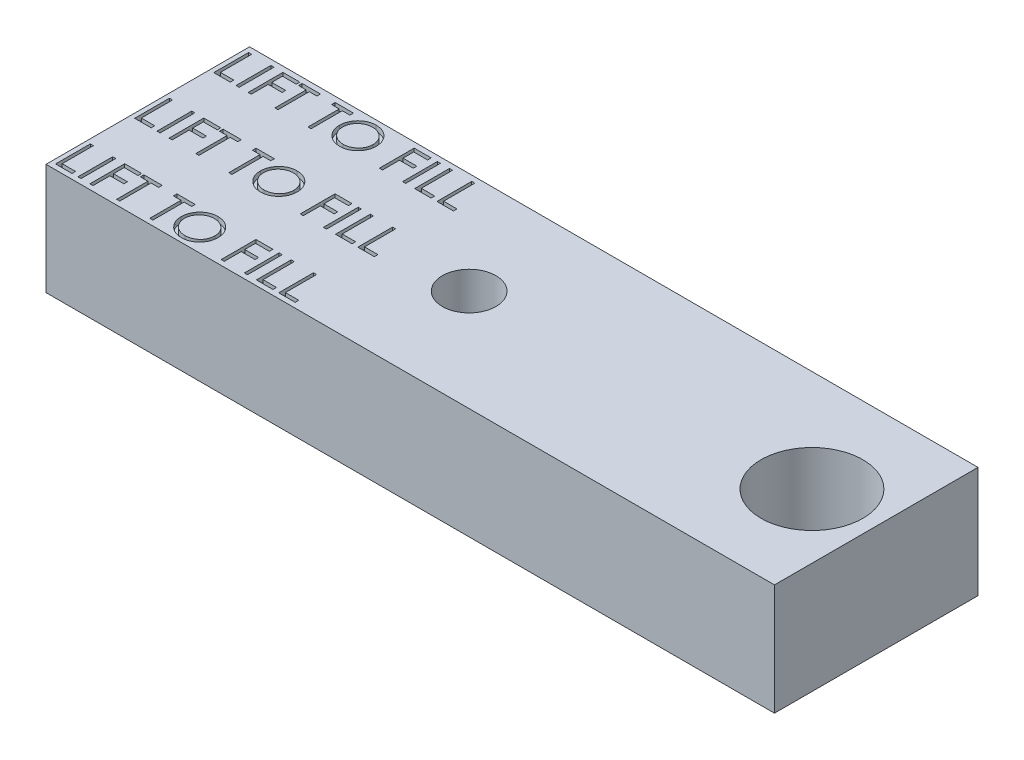
from build123d import *

# Parameters (mm, degrees)
SKETCH1_W           = 34.544
SKETCH1_H           = 9.652
BOSS_EXTRUDE1_DEPTH = 5.2705
SKETCH2_R           = 2.413
SKETCH2_R_2         = 1.27
CUT_EXTRUDE1_DEPTH  = 6.2705
SKETCH3_W           = 0.148166667
SKETCH3_H           = 1.651
SKETCH3_W_2         = 0.148166666
CUT_EXTRUDE2_DEPTH  = 0.254


with BuildPart() as part:
    # Sketch1 → Boss-Extrude1 (new body)
    with BuildSketch(Plane(origin=(0, 0, 0), x_dir=(1, 0, 0), z_dir=(0, 1, 0))):
        with Locations((17.272, 4.826)):
            Rectangle(SKETCH1_W, SKETCH1_H)
    extrude(amount=BOSS_EXTRUDE1_DEPTH)

    # Sketch2 → Cut-Extrude1 (cut, through all)
    with BuildSketch(Plane(origin=(0, 5.2705, 0), x_dir=(1, 0, 0), z_dir=(0, 1, 0))):
        with Locations((31.496, 4.826)):
            Circle(SKETCH2_R)
        with Locations((15.24, 4.826)):
            Circle(SKETCH2_R_2)
    extrude(amount=-CUT_EXTRUDE1_DEPTH, mode=Mode.SUBTRACT)

    # Sketch3 → Cut-Extrude2 (cut)
    with BuildSketch(Plane(origin=(0, 5.2705, 0), x_dir=(1, 0, 0), z_dir=(0, 1, 0))):
        Polygon((0.211666667, 9.394066324), (0.359833333, 9.394066324), (0.359833333, 7.912399657), (0.994833333, 7.912399657), (0.994833333, 7.743066324), (0.211666667, 7.743066324), align=None)
        with Locations((1.344083333, 8.568566324)):
            Rectangle(SKETCH3_W, SKETCH3_H)
        Polygon((1.8415, 9.394066324), (2.645833333, 9.394066324), (2.645833333, 9.224732991), (1.989666667, 9.224732991), (1.989666667, 8.716732991), (2.645833333, 8.716732991), (2.645833333, 8.547399657), (1.989666667, 8.547399657), (1.989666667, 7.743066324), (1.8415, 7.743066324), align=None)
        Polygon((2.751666667, 9.224732991), (2.751666667, 9.394066324), (3.6195, 9.394066324), (3.6195, 9.224732991), (3.259666667, 9.224732991), (3.259666667, 7.743066324), (3.1115, 7.743066324), (3.1115, 9.224732991), align=None)
        Polygon((4.318, 9.224732991), (4.318, 9.394066324), (5.185833333, 9.394066324), (5.185833333, 9.224732991), (4.826, 9.224732991), (4.826, 7.743066324), (4.677833333, 7.743066324), (4.677833333, 9.224732991), align=None)
        with BuildLine():
            add(Edge.make_bspline(
                [(6.212416667, 9.436399657), (6.242987576, 9.435625348), (6.303031364, 9.434104541), (6.391277266, 9.422463055), (6.475523124, 9.40232303), (6.556455209, 9.375499948), (6.633105468, 9.339718351), (6.706050842, 9.296469157), (6.775117774, 9.245299262), (6.839375345, 9.186604218), (6.898177809, 9.122741909), (6.949984249, 9.054589614), (6.993401914, 8.982559408), (7.029056809, 8.906867742), (7.057028811, 8.827685797), (7.076330908, 8.744591437), (7.088660647, 8.658123053), (7.090102101, 8.599146095), (7.090833333, 8.569227782)],
                knots=[0, 0, 0, 0, 9.1698e-05, 0.000180102, 0.000266419, 0.000351239, 0.000435435, 0.000519665, 0.000605259, 0.000692824, 0.000780368, 0.000865366, 0.000949198, 0.001032196, 0.00111598, 0.001200612, 0.00128775, 0.001377465, 0.001377465, 0.001377465, 0.001377465], degree=3))
            add(Edge.make_bspline(
                [(7.090833333, 8.569227782), (7.090102208, 8.539529855), (7.088661075, 8.480991801), (7.076316889, 8.395072136), (7.056957263, 8.312479354), (7.029316567, 8.233351333), (6.993831634, 8.157604602), (6.950124867, 8.08543847), (6.898641398, 8.016829279), (6.840051252, 7.952528648), (6.776180646, 7.893565555), (6.707673455, 7.842186965), (6.636070377, 7.797975957), (6.560449998, 7.76269943), (6.481815209, 7.734504161), (6.399462233, 7.715280563), (6.313776959, 7.702880589), (6.255345237, 7.701456712), (6.225645833, 7.700732991)],
                knots=[0, 0, 0, 0, 8.9055e-05, 0.000175537, 0.000259847, 0.00034321, 0.000426507, 0.000510339, 0.000595865, 0.000683431, 0.000770974, 0.000856237, 0.000939957, 0.001022955, 0.001106116, 0.001190104, 0.001276259, 0.001365313, 0.001365313, 0.001365313, 0.001365313], degree=3))
            add(Edge.make_bspline(
                [(6.225645833, 7.700732991), (6.195727676, 7.701463858), (6.136751024, 7.702904594), (6.050173982, 7.715254736), (5.967021252, 7.734567334), (5.887530625, 7.762167071), (5.811657774, 7.797836799), (5.73925431, 7.841330922), (5.670610849, 7.892939833), (5.6062965, 7.95151098), (5.547450521, 8.015273332), (5.496147169, 8.08359372), (5.452643266, 8.155131765), (5.417093305, 8.230085997), (5.388948728, 8.308094069), (5.369747683, 8.389676337), (5.357324639, 8.474367686), (5.355893058, 8.532031408), (5.355166667, 8.561290282)],
                knots=[0, 0, 0, 0, 8.9715e-05, 0.000176853, 0.000261807, 0.000345482, 0.000428779, 0.000512894, 0.000598421, 0.000685986, 0.00077353, 0.000858329, 0.000941878, 0.001024278, 0.001106815, 0.00119016, 0.001275332, 0.001363065, 0.001363065, 0.001363065, 0.001363065], degree=3))
            add(Edge.make_bspline(
                [(5.355166667, 8.561290282), (5.355418862, 8.580929007), (5.355920071, 8.619958705), (5.361954095, 8.677916636), (5.370709914, 8.734942486), (5.383258417, 8.790874096), (5.399670143, 8.845574549), (5.419034971, 8.899421095), (5.442686652, 8.951868046), (5.469423723, 9.003163857), (5.499265222, 9.0525089), (5.532226611, 9.099151812), (5.567150152, 9.143483991), (5.605436084, 9.184356621), (5.645822585, 9.222958725), (5.688964808, 9.258697081), (5.734599507, 9.291893951), (5.782923041, 9.321810232), (5.83274469, 9.348867355), (5.884103422, 9.372086005), (5.936301707, 9.392014076), (5.989584028, 9.408165963), (6.043808893, 9.42091736), (6.099094649, 9.429600372), (6.155397252, 9.435649786), (6.19332842, 9.436148625), (6.212416667, 9.436399657)],
                knots=[0, 0, 0, 0, 5.8893e-05, 0.000117043, 0.000174625, 0.000231914, 0.00028884, 0.00034586, 0.000403451, 0.000461292, 0.000519317, 0.000576296, 0.000632544, 0.000688477, 0.000744153, 0.000800049, 0.000856413, 0.000913311, 0.000970431, 0.001026378, 0.001082274, 0.001137933, 0.001193287, 0.001249236, 0.001305741, 0.001362981, 0.001362981, 0.001362981, 0.001362981], degree=3))
        make_face()
        with BuildLine():
            add(Edge.make_bspline(
                [(6.219692708, 9.267066324), (6.204024891, 9.266875331), (6.172839042, 9.266495172), (6.126476823, 9.261487588), (6.080724342, 9.254350603), (6.035572151, 9.244170291), (5.991209173, 9.230299979), (5.947221891, 9.214336739), (5.904011422, 9.194892162), (5.861720416, 9.172923152), (5.820721333, 9.14860679), (5.782034771, 9.121732393), (5.745560575, 9.092930201), (5.711388051, 9.062132996), (5.679617541, 9.029183941), (5.649623729, 8.994582549), (5.622608849, 8.957339814), (5.597850653, 8.918465647), (5.575695252, 8.878010684), (5.555993937, 8.836400832), (5.539878286, 8.793296672), (5.526735205, 8.749165839), (5.515838694, 8.704078228), (5.508935663, 8.657691803), (5.503873056, 8.610239652), (5.503514626, 8.57817164), (5.503333333, 8.561951741)],
                knots=[0, 0, 0, 0, 4.6982e-05, 9.3515e-05, 0.000139732, 0.000185865, 0.000232211, 0.000279088, 0.000326168, 0.000374243, 0.000422001, 0.000469065, 0.000515448, 0.000561345, 0.000606953, 0.000652691, 0.000698599, 0.000744841, 0.000790874, 0.000836888, 0.000882836, 0.000928769, 0.000974976, 0.001021847, 0.001069367, 0.001118002, 0.001118002, 0.001118002, 0.001118002], degree=3))
            add(Edge.make_bspline(
                [(5.503333333, 8.561951741), (5.503934704, 8.538100819), (5.505117786, 8.491178677), (5.515475485, 8.422417761), (5.531429794, 8.356336115), (5.554948226, 8.293295317), (5.584359902, 8.232753486), (5.620694586, 8.175247691), (5.663742801, 8.120762392), (5.712642367, 8.069677966), (5.766098307, 8.023050988), (5.822860974, 7.982123449), (5.882322262, 7.947494785), (5.94463723, 7.919283878), (6.009473197, 7.896929462), (6.077247951, 7.881608828), (6.14751001, 7.87152572), (6.195403471, 7.870557406), (6.219692708, 7.870066324)],
                knots=[0, 0, 0, 0, 7.1514e-05, 0.00014069, 0.00020815, 0.000275118, 0.000342122, 0.000409748, 0.000478756, 0.000550102, 0.000621599, 0.000691264, 0.000759732, 0.000827667, 0.000896173, 0.000965087, 0.001035854, 0.001108676, 0.001108676, 0.001108676, 0.001108676], degree=3))
            add(Edge.make_bspline(
                [(6.219692708, 7.870066324), (6.236018505, 7.870290626), (6.268397462, 7.870735485), (6.316557379, 7.875216146), (6.363849666, 7.882401237), (6.410207991, 7.89274624), (6.455579741, 7.90569348), (6.500154289, 7.921075011), (6.543456854, 7.940264916), (6.586033709, 7.961467506), (6.62678805, 7.985638221), (6.665692937, 8.011600502), (6.701767749, 8.040360272), (6.735914709, 8.070699903), (6.767815656, 8.103231135), (6.797254865, 8.137911674), (6.824133207, 8.174960424), (6.848882002, 8.213775625), (6.87095977, 8.254341286), (6.890195854, 8.296102), (6.906515336, 8.338954936), (6.91968961, 8.382961903), (6.930013295, 8.42803932), (6.937126709, 8.474247545), (6.942102558, 8.521494138), (6.942477607, 8.553449883), (6.942666667, 8.569558511)],
                knots=[0, 0, 0, 0, 4.8966e-05, 9.7114e-05, 0.000144965, 0.000192388, 0.000239498, 0.000286463, 0.000333712, 0.000381486, 0.000429076, 0.000475766, 0.000521685, 0.00056736, 0.000612732, 0.000658255, 0.000703701, 0.000749942, 0.000796266, 0.000842141, 0.000887779, 0.000933712, 0.000979845, 0.001026389, 0.001073909, 0.001122214, 0.001122214, 0.001122214, 0.001122214], degree=3))
            add(Edge.make_bspline(
                [(6.942666667, 8.569558511), (6.942477456, 8.585556939), (6.942102122, 8.617292768), (6.937129086, 8.664209857), (6.93000578, 8.710085586), (6.91974, 8.754739854), (6.906508342, 8.798184044), (6.890193004, 8.840377353), (6.870953995, 8.881476967), (6.848873887, 8.921381306), (6.824054252, 8.959672589), (6.796933396, 8.996278756), (6.767043056, 9.030512355), (6.735237237, 9.06321852), (6.700721485, 9.093699702), (6.66365215, 9.121966011), (6.624479261, 9.148699604), (6.583002728, 9.172816262), (6.540197509, 9.19508789), (6.496274325, 9.214169206), (6.451730769, 9.230383026), (6.406680115, 9.244212257), (6.360743173, 9.254310731), (6.314230339, 9.261494019), (6.267205963, 9.266493429), (6.235580718, 9.266874753), (6.219692708, 9.267066324)],
                knots=[0, 0, 0, 0, 4.7974e-05, 9.5165e-05, 0.000141382, 0.000187193, 0.000232493, 0.000277513, 0.000322788, 0.000368532, 0.000414217, 0.000459593, 0.00050508, 0.000550451, 0.000596374, 0.000643076, 0.000690225, 0.000738553, 0.000786922, 0.000834909, 0.000882097, 0.000929076, 0.000976177, 0.001023047, 0.001070238, 0.001117881, 0.001117881, 0.001117881, 0.001117881], degree=3))
        make_face(mode=Mode.SUBTRACT)
        Polygon((8.0645, 9.394066324), (8.868833333, 9.394066324), (8.868833333, 9.224732991), (8.212666667, 9.224732991), (8.212666667, 8.716732991), (8.868833333, 8.716732991), (8.868833333, 8.547399657), (8.212666667, 8.547399657), (8.212666667, 7.743066324), (8.0645, 7.743066324), align=None)
        with Locations((9.23925, 8.568566324)):
            Rectangle(SKETCH3_W_2, SKETCH3_H)
        Polygon((9.736666667, 9.394066324), (9.884833333, 9.394066324), (9.884833333, 7.912399657), (10.519833333, 7.912399657), (10.519833333, 7.743066324), (9.736666667, 7.743066324), align=None)
        Polygon((10.795, 9.394066324), (10.943166667, 9.394066324), (10.943166667, 7.912399657), (11.578166667, 7.912399657), (11.578166667, 7.743066324), (10.795, 7.743066324), align=None)
        Polygon((0.211666667, 5.642399657), (0.359833333, 5.642399657), (0.359833333, 4.160732991), (0.994833333, 4.160732991), (0.994833333, 3.991399657), (0.211666667, 3.991399657), align=None)
        with Locations((1.344083333, 4.816899657)):
            Rectangle(SKETCH3_W, SKETCH3_H)
        Polygon((1.8415, 5.642399657), (2.645833333, 5.642399657), (2.645833333, 5.473066324), (1.989666667, 5.473066324), (1.989666667, 4.965066324), (2.645833333, 4.965066324), (2.645833333, 4.795732991), (1.989666667, 4.795732991), (1.989666667, 3.991399657), (1.8415, 3.991399657), align=None)
        Polygon((2.751666667, 5.473066324), (2.751666667, 5.642399657), (3.6195, 5.642399657), (3.6195, 5.473066324), (3.259666667, 5.473066324), (3.259666667, 3.991399657), (3.1115, 3.991399657), (3.1115, 5.473066324), align=None)
        Polygon((4.318, 5.473066324), (4.318, 5.642399657), (5.185833333, 5.642399657), (5.185833333, 5.473066324), (4.826, 5.473066324), (4.826, 3.991399657), (4.677833333, 3.991399657), (4.677833333, 5.473066324), align=None)
        with BuildLine():
            add(Edge.make_bspline(
                [(6.212416667, 5.684732991), (6.242987576, 5.683958681), (6.303031364, 5.682437874), (6.391277266, 5.670796388), (6.475523124, 5.650656363), (6.556455209, 5.623833282), (6.633105468, 5.588051684), (6.706050842, 5.54480249), (6.775117774, 5.493632595), (6.839375345, 5.434937551), (6.898177809, 5.371075242), (6.949984249, 5.302922948), (6.993401914, 5.230892741), (7.029056809, 5.155201075), (7.057028811, 5.07601913), (7.076330908, 4.992924771), (7.088660647, 4.906456386), (7.090102101, 4.847479428), (7.090833333, 4.817561116)],
                knots=[0, 0, 0, 0, 9.1698e-05, 0.000180102, 0.000266419, 0.000351239, 0.000435435, 0.000519665, 0.000605259, 0.000692824, 0.000780368, 0.000865366, 0.000949198, 0.001032196, 0.00111598, 0.001200612, 0.00128775, 0.001377465, 0.001377465, 0.001377465, 0.001377465], degree=3))
            add(Edge.make_bspline(
                [(7.090833333, 4.817561116), (7.090102208, 4.787863189), (7.088661075, 4.729325134), (7.076316889, 4.64340547), (7.056957263, 4.560812687), (7.029316567, 4.481684666), (6.993831634, 4.405937935), (6.950124867, 4.333771804), (6.898641398, 4.265162613), (6.840051252, 4.200861981), (6.776180646, 4.141898888), (6.707673455, 4.090520299), (6.636070377, 4.04630929), (6.560449998, 4.011032763), (6.481815209, 3.982837494), (6.399462233, 3.963613896), (6.313776959, 3.951213923), (6.255345237, 3.949790045), (6.225645833, 3.949066324)],
                knots=[0, 0, 0, 0, 8.9055e-05, 0.000175537, 0.000259847, 0.00034321, 0.000426507, 0.000510339, 0.000595865, 0.000683431, 0.000770974, 0.000856237, 0.000939957, 0.001022955, 0.001106116, 0.001190104, 0.001276259, 0.001365313, 0.001365313, 0.001365313, 0.001365313], degree=3))
            add(Edge.make_bspline(
                [(6.225645833, 3.949066324), (6.195727676, 3.949797192), (6.136751024, 3.951237927), (6.050173982, 3.96358807), (5.967021252, 3.982900668), (5.887530625, 4.010500404), (5.811657774, 4.046170132), (5.73925431, 4.089664255), (5.670610849, 4.141273167), (5.6062965, 4.199844314), (5.547450521, 4.263606666), (5.496147169, 4.331927053), (5.452643266, 4.403465098), (5.417093305, 4.47841933), (5.388948728, 4.556427402), (5.369747683, 4.63800967), (5.357324639, 4.72270102), (5.355893058, 4.780364741), (5.355166667, 4.809623616)],
                knots=[0, 0, 0, 0, 8.9715e-05, 0.000176853, 0.000261807, 0.000345482, 0.000428779, 0.000512894, 0.000598421, 0.000685986, 0.00077353, 0.000858329, 0.000941878, 0.001024278, 0.001106815, 0.00119016, 0.001275332, 0.001363065, 0.001363065, 0.001363065, 0.001363065], degree=3))
            add(Edge.make_bspline(
                [(5.355166667, 4.809623616), (5.355418862, 4.82926234), (5.355920071, 4.868292039), (5.361954095, 4.926249969), (5.370709914, 4.983275819), (5.383258417, 5.039207429), (5.399670143, 5.093907882), (5.419034971, 5.147754428), (5.442686652, 5.200201379), (5.469423723, 5.25149719), (5.499265222, 5.300842234), (5.532226611, 5.347485146), (5.567150152, 5.391817324), (5.605436084, 5.432689954), (5.645822585, 5.471292059), (5.688964808, 5.507030415), (5.734599507, 5.540227284), (5.782923041, 5.570143565), (5.83274469, 5.597200689), (5.884103422, 5.620419339), (5.936301707, 5.64034741), (5.989584028, 5.656499296), (6.043808893, 5.669250693), (6.099094649, 5.677933705), (6.155397252, 5.683983119), (6.19332842, 5.684481958), (6.212416667, 5.684732991)],
                knots=[0, 0, 0, 0, 5.8893e-05, 0.000117043, 0.000174625, 0.000231914, 0.00028884, 0.00034586, 0.000403451, 0.000461292, 0.000519317, 0.000576296, 0.000632544, 0.000688477, 0.000744153, 0.000800049, 0.000856413, 0.000913311, 0.000970431, 0.001026378, 0.001082274, 0.001137933, 0.001193287, 0.001249236, 0.001305741, 0.001362981, 0.001362981, 0.001362981, 0.001362981], degree=3))
        make_face()
        with BuildLine():
            add(Edge.make_bspline(
                [(6.219692708, 5.515399657), (6.204024891, 5.515208665), (6.172839042, 5.514828506), (6.126476823, 5.509820921), (6.080724342, 5.502683936), (6.035572151, 5.492503624), (5.991209173, 5.478633313), (5.947221891, 5.462670073), (5.904011422, 5.443225496), (5.861720416, 5.421256486), (5.820721333, 5.396940123), (5.782034771, 5.370065727), (5.745560575, 5.341263534), (5.711388051, 5.310466329), (5.679617541, 5.277517274), (5.649623729, 5.242915882), (5.622608849, 5.205673147), (5.597850653, 5.166798981), (5.575695252, 5.126344018), (5.555993937, 5.084734166), (5.539878286, 5.041630005), (5.526735205, 4.997499173), (5.515838694, 4.952411561), (5.508935663, 4.906025136), (5.503873056, 4.858572985), (5.503514626, 4.826504973), (5.503333333, 4.810285074)],
                knots=[0, 0, 0, 0, 4.6982e-05, 9.3515e-05, 0.000139732, 0.000185865, 0.000232211, 0.000279088, 0.000326168, 0.000374243, 0.000422001, 0.000469065, 0.000515448, 0.000561345, 0.000606953, 0.000652691, 0.000698599, 0.000744841, 0.000790874, 0.000836888, 0.000882836, 0.000928769, 0.000974976, 0.001021847, 0.001069367, 0.001118002, 0.001118002, 0.001118002, 0.001118002], degree=3))
            add(Edge.make_bspline(
                [(5.503333333, 4.810285074), (5.503934704, 4.786434152), (5.505117786, 4.73951201), (5.515475485, 4.670751094), (5.531429794, 4.604669448), (5.554948226, 4.541628651), (5.584359902, 4.481086819), (5.620694586, 4.423581024), (5.663742801, 4.369095725), (5.712642367, 4.3180113), (5.766098307, 4.271384322), (5.822860974, 4.230456782), (5.882322262, 4.195828119), (5.94463723, 4.167617212), (6.009473197, 4.145262795), (6.077247951, 4.129942161), (6.14751001, 4.119859053), (6.195403471, 4.118890739), (6.219692708, 4.118399657)],
                knots=[0, 0, 0, 0, 7.1514e-05, 0.00014069, 0.00020815, 0.000275118, 0.000342122, 0.000409748, 0.000478756, 0.000550102, 0.000621599, 0.000691264, 0.000759732, 0.000827667, 0.000896173, 0.000965087, 0.001035854, 0.001108676, 0.001108676, 0.001108676, 0.001108676], degree=3))
            add(Edge.make_bspline(
                [(6.219692708, 4.118399657), (6.236018505, 4.118623959), (6.268397462, 4.119068818), (6.316557379, 4.12354948), (6.363849666, 4.13073457), (6.410207991, 4.141079574), (6.455579741, 4.154026813), (6.500154289, 4.169408344), (6.543456854, 4.188598249), (6.586033709, 4.20980084), (6.62678805, 4.233971554), (6.665692937, 4.259933836), (6.701767749, 4.288693605), (6.735914709, 4.319033236), (6.767815656, 4.351564468), (6.797254865, 4.386245007), (6.824133207, 4.423293757), (6.848882002, 4.462108959), (6.87095977, 4.502674619), (6.890195854, 4.544435333), (6.906515336, 4.587288269), (6.91968961, 4.631295236), (6.930013295, 4.676372654), (6.937126709, 4.722580879), (6.942102558, 4.769827471), (6.942477607, 4.801783216), (6.942666667, 4.817891845)],
                knots=[0, 0, 0, 0, 4.8966e-05, 9.7114e-05, 0.000144965, 0.000192388, 0.000239498, 0.000286463, 0.000333712, 0.000381486, 0.000429076, 0.000475766, 0.000521685, 0.00056736, 0.000612732, 0.000658255, 0.000703701, 0.000749942, 0.000796266, 0.000842141, 0.000887779, 0.000933712, 0.000979845, 0.001026389, 0.001073909, 0.001122214, 0.001122214, 0.001122214, 0.001122214], degree=3))
            add(Edge.make_bspline(
                [(6.942666667, 4.817891845), (6.942477456, 4.833890273), (6.942102122, 4.865626101), (6.937129086, 4.91254319), (6.93000578, 4.958418919), (6.91974, 5.003073188), (6.906508342, 5.046517377), (6.890193004, 5.088710686), (6.870953995, 5.129810301), (6.848873887, 5.169714639), (6.824054252, 5.208005922), (6.796933396, 5.244612089), (6.767043056, 5.278845688), (6.735237237, 5.311551854), (6.700721485, 5.342033035), (6.66365215, 5.370299344), (6.624479261, 5.397032937), (6.583002728, 5.421149595), (6.540197509, 5.443421223), (6.496274325, 5.462502539), (6.451730769, 5.478716359), (6.406680115, 5.49254559), (6.360743173, 5.502644064), (6.314230339, 5.509827353), (6.267205963, 5.514826763), (6.235580718, 5.515208086), (6.219692708, 5.515399657)],
                knots=[0, 0, 0, 0, 4.7974e-05, 9.5165e-05, 0.000141382, 0.000187193, 0.000232493, 0.000277513, 0.000322788, 0.000368532, 0.000414217, 0.000459593, 0.00050508, 0.000550451, 0.000596374, 0.000643076, 0.000690225, 0.000738553, 0.000786922, 0.000834909, 0.000882097, 0.000929076, 0.000976177, 0.001023047, 0.001070238, 0.001117881, 0.001117881, 0.001117881, 0.001117881], degree=3))
        make_face(mode=Mode.SUBTRACT)
        Polygon((8.0645, 5.642399657), (8.868833333, 5.642399657), (8.868833333, 5.473066324), (8.212666667, 5.473066324), (8.212666667, 4.965066324), (8.868833333, 4.965066324), (8.868833333, 4.795732991), (8.212666667, 4.795732991), (8.212666667, 3.991399657), (8.0645, 3.991399657), align=None)
        with Locations((9.23925, 4.816899657)):
            Rectangle(SKETCH3_W_2, SKETCH3_H)
        Polygon((9.736666667, 5.642399657), (9.884833333, 5.642399657), (9.884833333, 4.160732991), (10.519833333, 4.160732991), (10.519833333, 3.991399657), (9.736666667, 3.991399657), align=None)
        Polygon((10.795, 5.642399657), (10.943166667, 5.642399657), (10.943166667, 4.160732991), (11.578166667, 4.160732991), (11.578166667, 3.991399657), (10.795, 3.991399657), align=None)
        Polygon((0.211666667, 1.890732991), (0.359833333, 1.890732991), (0.359833333, 0.409066324), (0.994833333, 0.409066324), (0.994833333, 0.239732991), (0.211666667, 0.239732991), align=None)
        with Locations((1.344083333, 1.065232991)):
            Rectangle(SKETCH3_W, SKETCH3_H)
        Polygon((1.8415, 1.890732991), (2.645833333, 1.890732991), (2.645833333, 1.721399657), (1.989666667, 1.721399657), (1.989666667, 1.213399657), (2.645833333, 1.213399657), (2.645833333, 1.044066324), (1.989666667, 1.044066324), (1.989666667, 0.239732991), (1.8415, 0.239732991), align=None)
        Polygon((2.751666667, 1.721399657), (2.751666667, 1.890732991), (3.6195, 1.890732991), (3.6195, 1.721399657), (3.259666667, 1.721399657), (3.259666667, 0.239732991), (3.1115, 0.239732991), (3.1115, 1.721399657), align=None)
        Polygon((4.318, 1.721399657), (4.318, 1.890732991), (5.185833333, 1.890732991), (5.185833333, 1.721399657), (4.826, 1.721399657), (4.826, 0.239732991), (4.677833333, 0.239732991), (4.677833333, 1.721399657), align=None)
        with BuildLine():
            add(Edge.make_bspline(
                [(6.212416667, 1.933066324), (6.242987576, 1.932292015), (6.303031364, 1.930771207), (6.391277266, 1.919129722), (6.475523124, 1.898989696), (6.556455209, 1.872166615), (6.633105468, 1.836385018), (6.706050842, 1.793135824), (6.775117774, 1.741965928), (6.839375345, 1.683270884), (6.898177809, 1.619408575), (6.949984249, 1.551256281), (6.993401914, 1.479226075), (7.029056809, 1.403534408), (7.057028811, 1.324352464), (7.076330908, 1.241258104), (7.088660647, 1.15478972), (7.090102101, 1.095812761), (7.090833333, 1.065894449)],
                knots=[0, 0, 0, 0, 9.1698e-05, 0.000180102, 0.000266419, 0.000351239, 0.000435435, 0.000519665, 0.000605259, 0.000692824, 0.000780368, 0.000865366, 0.000949198, 0.001032196, 0.00111598, 0.001200612, 0.00128775, 0.001377465, 0.001377465, 0.001377465, 0.001377465], degree=3))
            add(Edge.make_bspline(
                [(7.090833333, 1.065894449), (7.090102208, 1.036196522), (7.088661075, 0.977658468), (7.076316889, 0.891738803), (7.056957263, 0.80914602), (7.029316567, 0.730017999), (6.993831634, 0.654271269), (6.950124867, 0.582105137), (6.898641398, 0.513495946), (6.840051252, 0.449195314), (6.776180646, 0.390232222), (6.707673455, 0.338853632), (6.636070377, 0.294642624), (6.560449998, 0.259366096), (6.481815209, 0.231170827), (6.399462233, 0.21194723), (6.313776959, 0.199547256), (6.255345237, 0.198123379), (6.225645833, 0.197399657)],
                knots=[0, 0, 0, 0, 8.9055e-05, 0.000175537, 0.000259847, 0.00034321, 0.000426507, 0.000510339, 0.000595865, 0.000683431, 0.000770974, 0.000856237, 0.000939957, 0.001022955, 0.001106116, 0.001190104, 0.001276259, 0.001365313, 0.001365313, 0.001365313, 0.001365313], degree=3))
            add(Edge.make_bspline(
                [(6.225645833, 0.197399657), (6.195727676, 0.198130525), (6.136751024, 0.19957126), (6.050173982, 0.211921403), (5.967021252, 0.231234001), (5.887530625, 0.258833738), (5.811657774, 0.294503466), (5.73925431, 0.337997589), (5.670610849, 0.3896065), (5.6062965, 0.448177647), (5.547450521, 0.511939999), (5.496147169, 0.580260386), (5.452643266, 0.651798432), (5.417093305, 0.726752664), (5.388948728, 0.804760736), (5.369747683, 0.886343003), (5.357324639, 0.971034353), (5.355893058, 1.028698075), (5.355166667, 1.057956949)],
                knots=[0, 0, 0, 0, 8.9715e-05, 0.000176853, 0.000261807, 0.000345482, 0.000428779, 0.000512894, 0.000598421, 0.000685986, 0.00077353, 0.000858329, 0.000941878, 0.001024278, 0.001106815, 0.00119016, 0.001275332, 0.001363065, 0.001363065, 0.001363065, 0.001363065], degree=3))
            add(Edge.make_bspline(
                [(5.355166667, 1.057956949), (5.355418862, 1.077595674), (5.355920071, 1.116625372), (5.361954095, 1.174583302), (5.370709914, 1.231609153), (5.383258417, 1.287540763), (5.399670143, 1.342241216), (5.419034971, 1.396087761), (5.442686652, 1.448534712), (5.469423723, 1.499830524), (5.499265222, 1.549175567), (5.532226611, 1.595818479), (5.567150152, 1.640150658), (5.605436084, 1.681023287), (5.645822585, 1.719625392), (5.688964808, 1.755363748), (5.734599507, 1.788560618), (5.782923041, 1.818476899), (5.83274469, 1.845534022), (5.884103422, 1.868752672), (5.936301707, 1.888680743), (5.989584028, 1.904832629), (6.043808893, 1.917584027), (6.099094649, 1.926267039), (6.155397252, 1.932316452), (6.19332842, 1.932815291), (6.212416667, 1.933066324)],
                knots=[0, 0, 0, 0, 5.8893e-05, 0.000117043, 0.000174625, 0.000231914, 0.00028884, 0.00034586, 0.000403451, 0.000461292, 0.000519317, 0.000576296, 0.000632544, 0.000688477, 0.000744153, 0.000800049, 0.000856413, 0.000913311, 0.000970431, 0.001026378, 0.001082274, 0.001137933, 0.001193287, 0.001249236, 0.001305741, 0.001362981, 0.001362981, 0.001362981, 0.001362981], degree=3))
        make_face()
        with BuildLine():
            add(Edge.make_bspline(
                [(6.219692708, 1.763732991), (6.204024891, 1.763541998), (6.172839042, 1.763161839), (6.126476823, 1.758154254), (6.080724342, 1.751017269), (6.035572151, 1.740836958), (5.991209173, 1.726966646), (5.947221891, 1.711003406), (5.904011422, 1.691558829), (5.861720416, 1.669589819), (5.820721333, 1.645273457), (5.782034771, 1.61839906), (5.745560575, 1.589596868), (5.711388051, 1.558799662), (5.679617541, 1.525850607), (5.649623729, 1.491249215), (5.622608849, 1.45400648), (5.597850653, 1.415132314), (5.575695252, 1.374677351), (5.555993937, 1.333067499), (5.539878286, 1.289963339), (5.526735205, 1.245832506), (5.515838694, 1.200744894), (5.508935663, 1.15435847), (5.503873056, 1.106906318), (5.503514626, 1.074838307), (5.503333333, 1.058618407)],
                knots=[0, 0, 0, 0, 4.6982e-05, 9.3515e-05, 0.000139732, 0.000185865, 0.000232211, 0.000279088, 0.000326168, 0.000374243, 0.000422001, 0.000469065, 0.000515448, 0.000561345, 0.000606953, 0.000652691, 0.000698599, 0.000744841, 0.000790874, 0.000836888, 0.000882836, 0.000928769, 0.000974976, 0.001021847, 0.001069367, 0.001118002, 0.001118002, 0.001118002, 0.001118002], degree=3))
            add(Edge.make_bspline(
                [(5.503333333, 1.058618407), (5.503934704, 1.034767485), (5.505117786, 0.987845343), (5.515475485, 0.919084428), (5.531429794, 0.853002782), (5.554948226, 0.789961984), (5.584359902, 0.729420152), (5.620694586, 0.671914358), (5.663742801, 0.617429058), (5.712642367, 0.566344633), (5.766098307, 0.519717655), (5.822860974, 0.478790116), (5.882322262, 0.444161452), (5.94463723, 0.415950545), (6.009473197, 0.393596129), (6.077247951, 0.378275494), (6.14751001, 0.368192387), (6.195403471, 0.367224072), (6.219692708, 0.366732991)],
                knots=[0, 0, 0, 0, 7.1514e-05, 0.00014069, 0.00020815, 0.000275118, 0.000342122, 0.000409748, 0.000478756, 0.000550102, 0.000621599, 0.000691264, 0.000759732, 0.000827667, 0.000896173, 0.000965087, 0.001035854, 0.001108676, 0.001108676, 0.001108676, 0.001108676], degree=3))
            add(Edge.make_bspline(
                [(6.219692708, 0.366732991), (6.236018505, 0.366957293), (6.268397462, 0.367402151), (6.316557379, 0.371882813), (6.363849666, 0.379067903), (6.410207991, 0.389412907), (6.455579741, 0.402360146), (6.500154289, 0.417741677), (6.543456854, 0.436931582), (6.586033709, 0.458134173), (6.62678805, 0.482304887), (6.665692937, 0.508267169), (6.701767749, 0.537026938), (6.735914709, 0.567366569), (6.767815656, 0.599897802), (6.797254865, 0.63457834), (6.824133207, 0.67162709), (6.848882002, 0.710442292), (6.87095977, 0.751007953), (6.890195854, 0.792768667), (6.906515336, 0.835621602), (6.91968961, 0.879628569), (6.930013295, 0.924705987), (6.937126709, 0.970914212), (6.942102558, 1.018160805), (6.942477607, 1.050116549), (6.942666667, 1.066225178)],
                knots=[0, 0, 0, 0, 4.8966e-05, 9.7114e-05, 0.000144965, 0.000192388, 0.000239498, 0.000286463, 0.000333712, 0.000381486, 0.000429076, 0.000475766, 0.000521685, 0.00056736, 0.000612732, 0.000658255, 0.000703701, 0.000749942, 0.000796266, 0.000842141, 0.000887779, 0.000933712, 0.000979845, 0.001026389, 0.001073909, 0.001122214, 0.001122214, 0.001122214, 0.001122214], degree=3))
            add(Edge.make_bspline(
                [(6.942666667, 1.066225178), (6.942477456, 1.082223606), (6.942102122, 1.113959435), (6.937129086, 1.160876523), (6.93000578, 1.206752253), (6.91974, 1.251406521), (6.906508342, 1.294850711), (6.890193004, 1.33704402), (6.870953995, 1.378143634), (6.848873887, 1.418047972), (6.824054252, 1.456339256), (6.796933396, 1.492945422), (6.767043056, 1.527179021), (6.735237237, 1.559885187), (6.700721485, 1.590366369), (6.66365215, 1.618632678), (6.624479261, 1.645366271), (6.583002728, 1.669482929), (6.540197509, 1.691754557), (6.496274325, 1.710835873), (6.451730769, 1.727049692), (6.406680115, 1.740878924), (6.360743173, 1.750977397), (6.314230339, 1.758160686), (6.267205963, 1.763160096), (6.235580718, 1.76354142), (6.219692708, 1.763732991)],
                knots=[0, 0, 0, 0, 4.7974e-05, 9.5165e-05, 0.000141382, 0.000187193, 0.000232493, 0.000277513, 0.000322788, 0.000368532, 0.000414217, 0.000459593, 0.00050508, 0.000550451, 0.000596374, 0.000643076, 0.000690225, 0.000738553, 0.000786922, 0.000834909, 0.000882097, 0.000929076, 0.000976177, 0.001023047, 0.001070238, 0.001117881, 0.001117881, 0.001117881, 0.001117881], degree=3))
        make_face(mode=Mode.SUBTRACT)
        Polygon((8.0645, 1.890732991), (8.868833333, 1.890732991), (8.868833333, 1.721399657), (8.212666667, 1.721399657), (8.212666667, 1.213399657), (8.868833333, 1.213399657), (8.868833333, 1.044066324), (8.212666667, 1.044066324), (8.212666667, 0.239732991), (8.0645, 0.239732991), align=None)
        with Locations((9.23925, 1.065232991)):
            Rectangle(SKETCH3_W_2, SKETCH3_H)
        Polygon((9.736666667, 1.890732991), (9.884833333, 1.890732991), (9.884833333, 0.409066324), (10.519833333, 0.409066324), (10.519833333, 0.239732991), (9.736666667, 0.239732991), align=None)
        Polygon((10.795, 1.890732991), (10.943166667, 1.890732991), (10.943166667, 0.409066324), (11.578166667, 0.409066324), (11.578166667, 0.239732991), (10.795, 0.239732991), align=None)
    extrude(amount=-CUT_EXTRUDE2_DEPTH, mode=Mode.SUBTRACT)


solid = part.part
